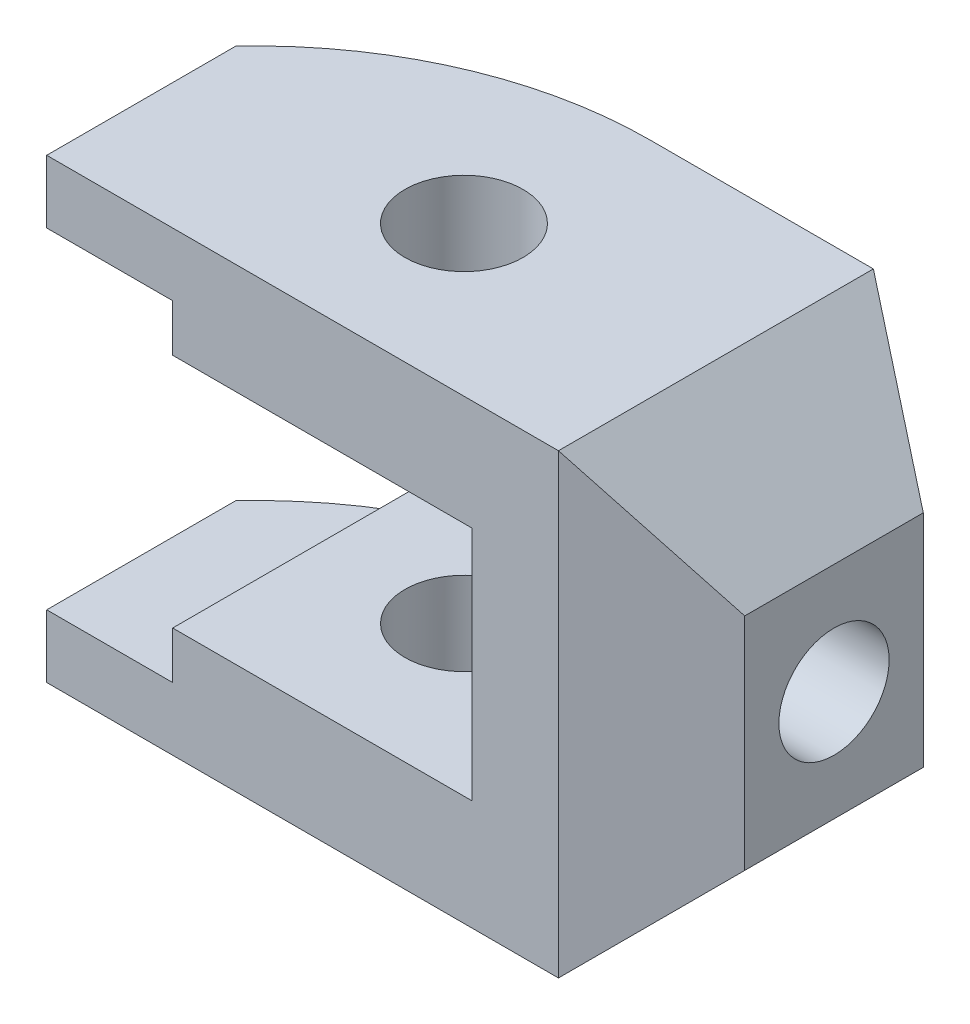
from build123d import *

# Parameters (mm, degrees)
SKETCH1_R           = 7.5
BOSS_EXTRUDE2_DEPTH = 58
CUT_EXTRUDE1_DEPTH  = 29
SKETCH6_R           = 7
CUT_EXTRUDE2_DEPTH  = 64
CUT_EXTRUDE3_DEPTH  = 64


with BuildPart() as part:
    # Sketch1 → Boss-Extrude2 (new body)
    with BuildSketch(Plane(origin=(0, 0, 0), x_dir=(1, 0, 0), z_dir=(0, 1, 0))):
        with BuildLine():
            Line((0, -19), (31, -19))
            Line((31, -19), (46, -10.339745962))
            Line((46, -10.339745962), (46, 12.339745962))
            Line((46, 12.339745962), (31, 21))
            Line((31, 21), (2.66060556, 21))
            ThreePointArc((2.66060556, 21), (-17.33939444, 16.82575695), (-34, 5))
            Line((-34, 5), (-34, -19))
            Line((-34, -19), (0, -19))
        make_face()
        Circle(SKETCH1_R, mode=Mode.SUBTRACT)
    extrude(amount=BOSS_EXTRUDE2_DEPTH)

    # Sketch4 → Cut-Extrude1 (cut, symmetric)
    with BuildSketch(Plane.XY):
        Polygon((31, 0), (46, 15), (46, 0), align=None)
        Polygon((31, 58), (46, 43), (46, 58), align=None)
    extrude(amount=CUT_EXTRUDE1_DEPTH, both=True, mode=Mode.SUBTRACT)

    # Sketch6 → Cut-Extrude2 (cut, symmetric)
    with BuildSketch(Plane(origin=(0, 0, 0), x_dir=(0, 0, -1), z_dir=(1, 0, 0))):
        with Locations((1, 29)):
            Circle(SKETCH6_R)
    extrude(amount=CUT_EXTRUDE2_DEPTH, both=True, mode=Mode.SUBTRACT)

    # Sketch7 → Cut-Extrude3 (cut, symmetric)
    with BuildSketch(Plane.XY.offset(19)):
        Polygon((-34, 50), (-18, 50), (-18, 44), (20, 44), (20, 14), (-18, 14), (-18, 8), (-34, 8), align=None)
    extrude(amount=CUT_EXTRUDE3_DEPTH, both=True, mode=Mode.SUBTRACT)


solid = part.part
